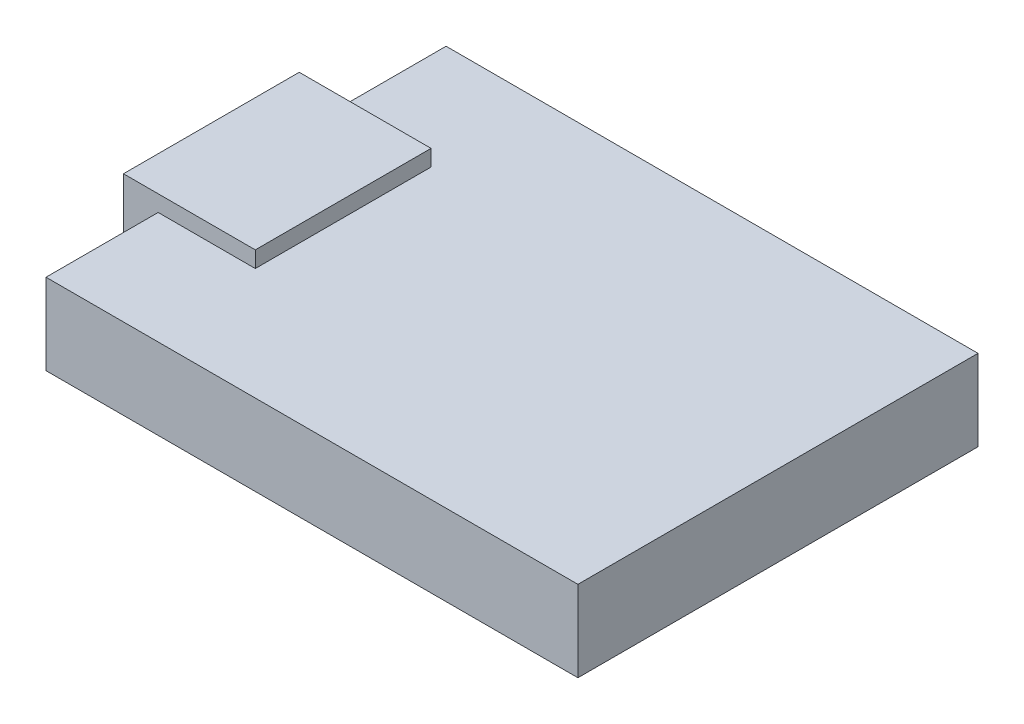
from build123d import *

# Parameters (mm, degrees)
SKETCH_1_W      = 23
SKETCH_1_H      = 17.3
EXTRUDE_1_DEPTH = 3.5
SKETCH_2_W      = 5.700101794
SKETCH_2_H      = 7.6
EXTRUDE_2_DEPTH = 0.7
SKETCH_3_W      = 1.500050897
SKETCH_3_H      = 7.6
EXTRUDE_3_DEPTH = 1.9


with BuildPart() as part:
    # Эскиз1 → Бобышка-Вытянуть1 (new body)
    with BuildSketch(Plane(origin=(0, 0, 0), x_dir=(1, 0, 0), z_dir=(0, 1, 0))):
        Rectangle(SKETCH_1_W, SKETCH_1_H)
    extrude(amount=EXTRUDE_1_DEPTH)

    # Эскиз2 → Бобышка-Вытянуть2 (add)
    with BuildSketch(Plane(origin=(0, 3.5, 0), x_dir=(1, 0, 0), z_dir=(0, 1, 0))):
        with Locations((-10.15, 0)):
            Rectangle(SKETCH_2_W, SKETCH_2_H)
    extrude(amount=EXTRUDE_2_DEPTH)

    # Эскиз3 → Бобышка-Вытянуть3 (add)
    with BuildSketch(Plane.XZ.offset(-3.5)):
        with Locations((-12.250025449, 0)):
            Rectangle(SKETCH_3_W, SKETCH_3_H)
    extrude(amount=EXTRUDE_3_DEPTH)


solid = part.part
